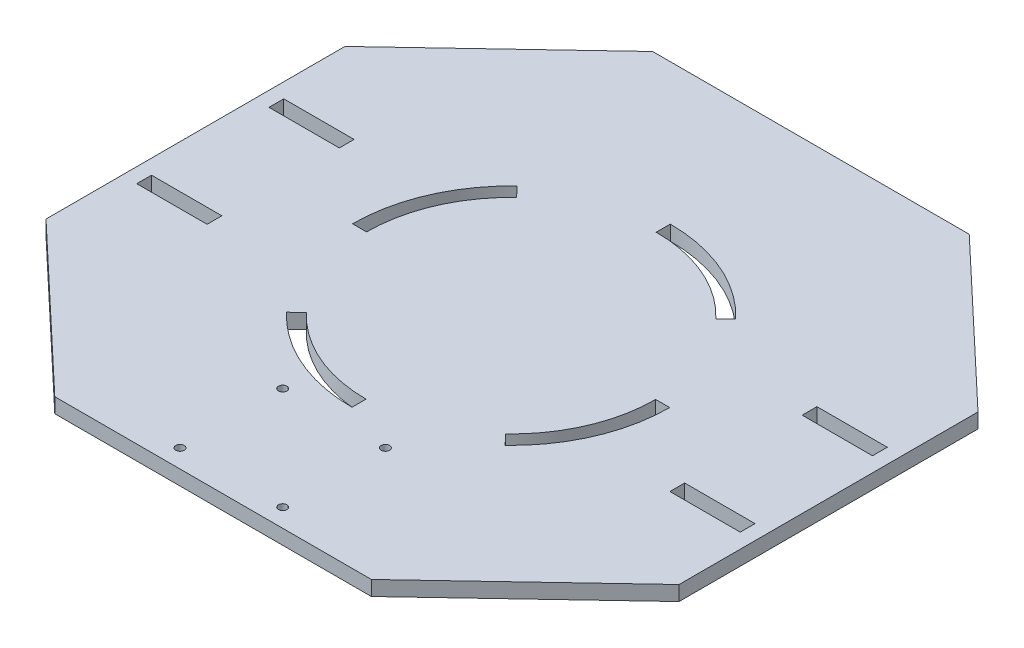
from build123d import *

# Parameters (mm, degrees)
SKETCH1_W           = 228.6
SKETCH1_H           = 215.9
BOSS_EXTRUDE1_DEPTH = 5.334
CUT_EXTRUDE1_DEPTH  = 6.334
CIRPATTERN1_COUNT   = 4
SKETCH8_W           = 25.4
SKETCH8_H           = 5.334
CUT_EXTRUDE2_DEPTH  = 6.334
SKETCH11_R          = 1.524
CUT_EXTRUDE4_DEPTH  = 6.334
CUT_EXTRUDE5_DEPTH  = 6.334


with BuildPart() as part:
    # Sketch1 → Boss-Extrude1 (new body)
    with BuildSketch(Plane(origin=(0, 0, 0), x_dir=(1, 0, 0), z_dir=(0, 1, 0))):
        with Locations((114.3, 107.95)):
            Rectangle(SKETCH1_W, SKETCH1_H)
    extrude(amount=BOSS_EXTRUDE1_DEPTH)

    # Sketch6 → Cut-Extrude1 (cut, through all)
    with BuildSketch(Plane(origin=(0, 5.334, 0), x_dir=(1, 0, 0), z_dir=(0, 1, 0))):
        with BuildLine():
            Line((114.3, 165.1), (114.3, 160.02))
            ThreePointArc((114.3, 160.02), (134.911318287, 155.766926485), (152.155574853, 143.702487361))
            Line((152.155574853, 143.702487361), (155.848801668, 147.190534909))
            ThreePointArc((155.848801668, 147.190534909), (136.922178608, 160.431992483), (114.3, 165.1))
        make_face()
    cut_extrude1 = extrude(amount=-CUT_EXTRUDE1_DEPTH, mode=Mode.SUBTRACT)

    # CirPattern1: Cut-Extrude1 ×4 about axis
    cirpattern1_axis = Axis((114.20329472, 0, -107.72565), (0, 1, 0))
    for i in range(1, CIRPATTERN1_COUNT):
        add(cut_extrude1.rotate(cirpattern1_axis, i * 360 / CIRPATTERN1_COUNT), mode=Mode.SUBTRACT)

    # Sketch8 → Cut-Extrude2 (cut, through all)
    with BuildSketch(Plane(origin=(0, 5.334, 0), x_dir=(1, 0, 0), z_dir=(0, 1, 0))):
        with Locations((18.034, 131.826)):
            Rectangle(SKETCH8_W, SKETCH8_H)
        with Locations((210.566, 131.826)):
            Rectangle(SKETCH8_W, SKETCH8_H)
        with Locations((210.566, 84.074)):
            Rectangle(SKETCH8_W, SKETCH8_H)
        with Locations((18.034, 84.074)):
            Rectangle(SKETCH8_W, SKETCH8_H)
    extrude(amount=-CUT_EXTRUDE2_DEPTH, mode=Mode.SUBTRACT)

    # Sketch11 → Cut-Extrude4 (cut, through all)
    with BuildSketch(Plane(origin=(0, 5.334, 0), x_dir=(1, 0, 0), z_dir=(0, 1, 0))):
        with Locations((95.758, 6.604)):
            Circle(SKETCH11_R)
        with Locations((132.842, 6.604)):
            Circle(SKETCH11_R)
        with Locations((132.842, 43.688)):
            Circle(SKETCH11_R)
        with Locations((95.758, 43.688)):
            Circle(SKETCH11_R)
    extrude(amount=-CUT_EXTRUDE4_DEPTH, mode=Mode.SUBTRACT)

    # Sketch13 → Cut-Extrude5 (cut, through all)
    with BuildSketch(Plane(origin=(0, 5.334, 0), x_dir=(1, 0, 0), z_dir=(0, 1, 0))):
        Polygon((0, 215.9), (0, 161.925), (57.15, 215.9), align=None)
        Polygon((228.6, 161.925), (171.45, 215.9), (228.6, 215.9), align=None)
        Polygon((228.6, 0), (228.6, 53.975), (171.45, 0), align=None)
        Polygon((0, 53.975), (57.15, 0), (0, 0), align=None)
    extrude(amount=-CUT_EXTRUDE5_DEPTH, mode=Mode.SUBTRACT)


solid = part.part
